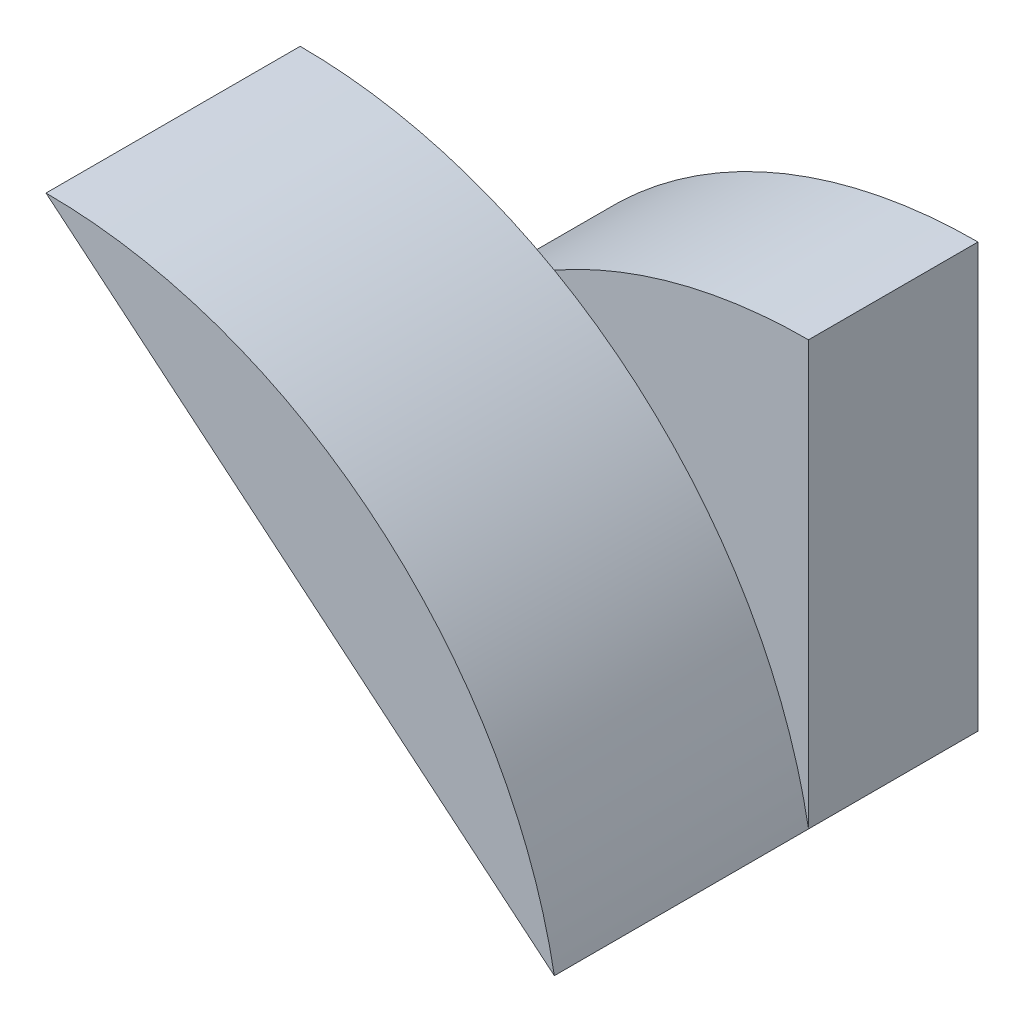
from build123d import *

# Parameters (mm, degrees)
BOSS_EXTRUDE1_DEPTH = 10
BOSS_EXTRUDE2_DEPTH = 15


with BuildPart() as part:
    # Sketch1 → Boss-Extrude1 (new body)
    with BuildSketch(Plane.XY):
        with BuildLine():
            Line((-30, 0), (0, 0))
            Line((0, 0), (0, 25))
            ThreePointArc((0, 25), (-19.52562419, 17.930749028), (-30, 0))
        make_face()
    extrude(amount=BOSS_EXTRUDE1_DEPTH)

    # Sketch2 → Boss-Extrude2 (add)
    with BuildSketch(Plane.XY.offset(10)):
        with BuildLine():
            Line((-30, 25), (0, 0))
            ThreePointArc((0, 0), (-10.47437581, 17.930749028), (-30, 25))
        make_face()
    extrude(amount=BOSS_EXTRUDE2_DEPTH)


solid = part.part
